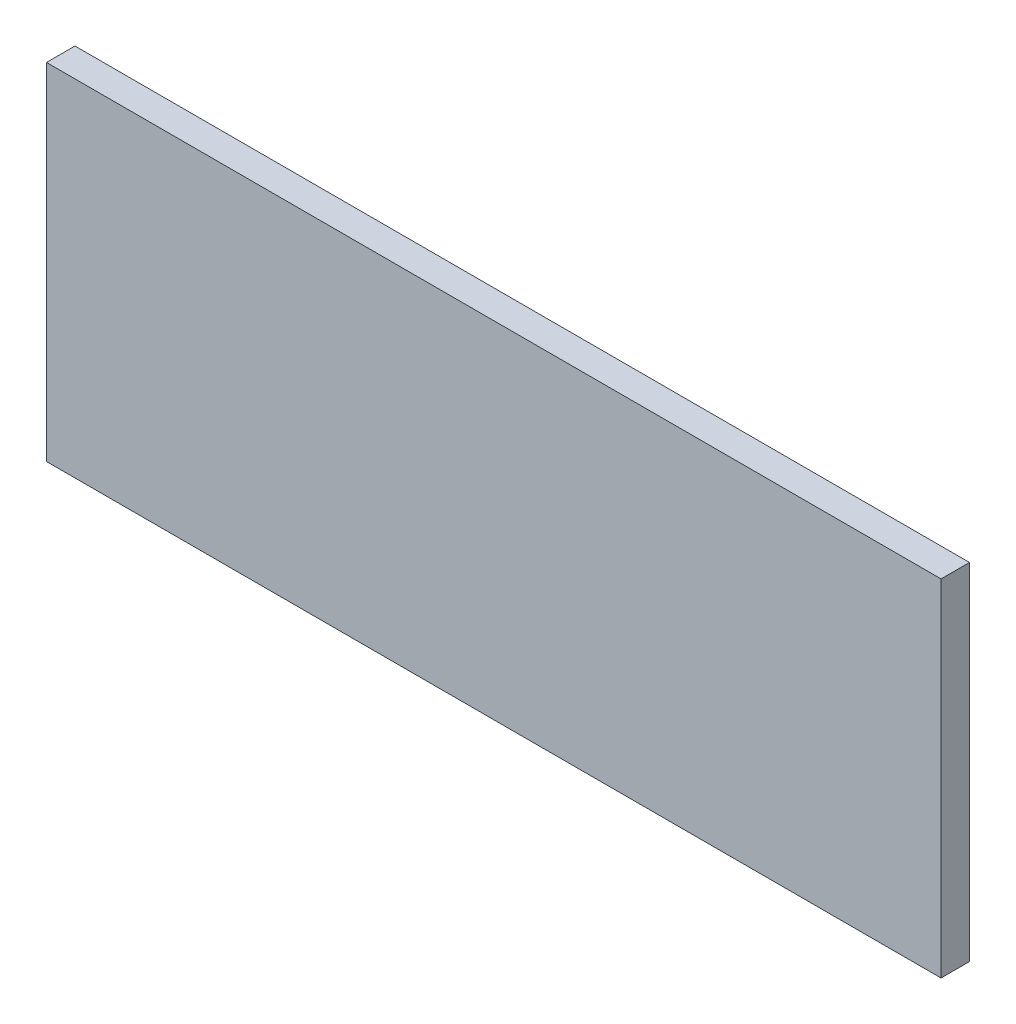
from build123d import *

# Parameters (mm, degrees)
IZIM1_W                     = 88
IZIM1_H                     = 34
Y_KSEKLIK_EKSTR_ZYON1_DEPTH = 2.8


with BuildPart() as part:
    # Çizim1 → Yükseklik-Ekstrüzyon1 (new body)
    with BuildSketch(Plane.XY):
        Rectangle(IZIM1_W, IZIM1_H)
    extrude(amount=Y_KSEKLIK_EKSTR_ZYON1_DEPTH)


solid = part.part
